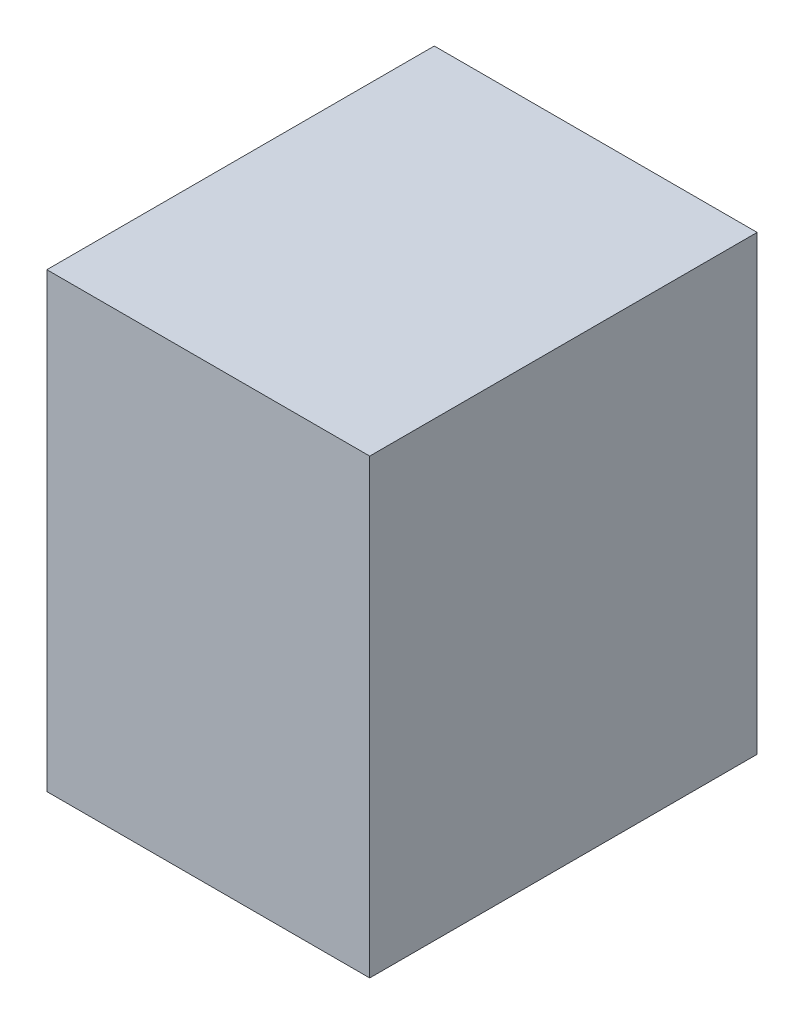
from build123d import *

# Parameters (mm, degrees)
IZIM1_W                     = 50
IZIM1_H                     = 70
Y_KSEKLIK_EKSTR_ZYON1_DEPTH = 60


with BuildPart() as part:
    # Çizim1 → Yükseklik-Ekstrüzyon1 (new body)
    with BuildSketch(Plane.XY):
        with Locations((-40.351427157, 0.994318182)):
            Rectangle(IZIM1_W, IZIM1_H)
    extrude(amount=Y_KSEKLIK_EKSTR_ZYON1_DEPTH)


solid = part.part
